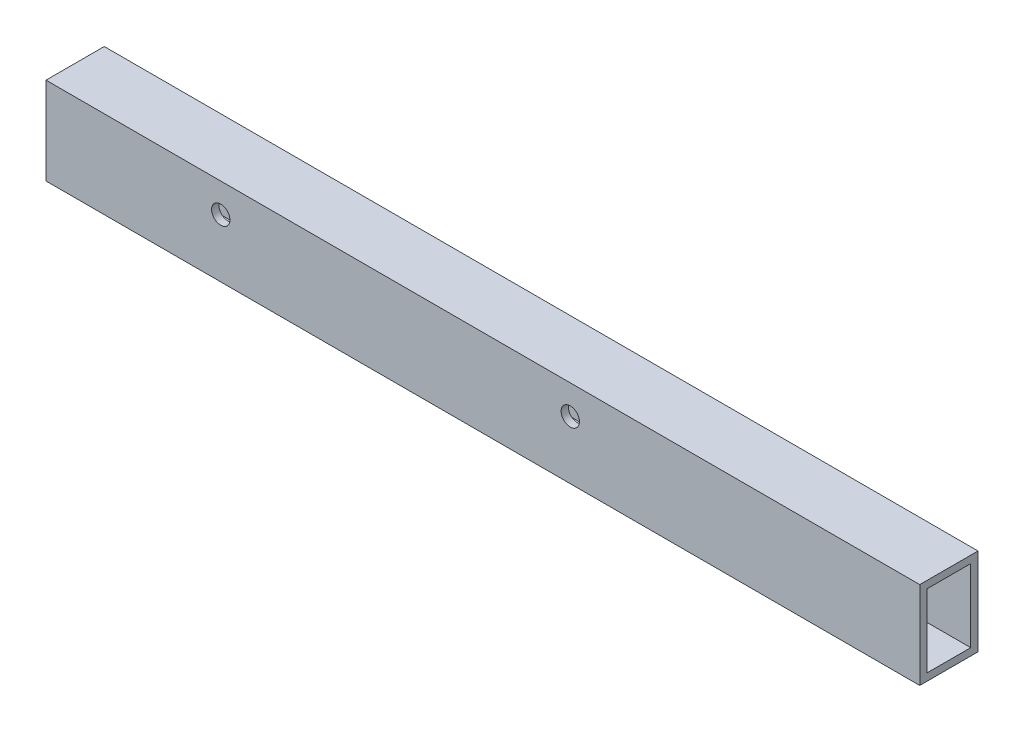
from build123d import *

# Parameters (mm, degrees)
SKETCH1_W           = 25.4
SKETCH1_H           = 38.1
SKETCH1_W_2         = 19.05
SKETCH1_H_2         = 31.75
BOSS_EXTRUDE1_DEPTH = 381
SKETCH2_R           = 4
CUT_EXTRUDE1_DEPTH  = 26.4


with BuildPart() as part:
    # Sketch1 → Boss-Extrude1 (new body)
    with BuildSketch(Plane(origin=(0, 0, 0), x_dir=(0, 0, -1), z_dir=(1, 0, 0))):
        Rectangle(SKETCH1_W, SKETCH1_H)
        Rectangle(SKETCH1_W_2, SKETCH1_H_2, mode=Mode.SUBTRACT)
    extrude(amount=BOSS_EXTRUDE1_DEPTH)

    # Sketch2 → Cut-Extrude1 (cut, through all)
    with BuildSketch(Plane(origin=(0, 0, -12.7), x_dir=(-1, 0, 0), z_dir=(0, 0, -1))):
        with Locations((-76.2, 6.35)):
            Circle(SKETCH2_R)
        with Locations((-228.6, 6.35)):
            Circle(SKETCH2_R)
    extrude(amount=-CUT_EXTRUDE1_DEPTH, mode=Mode.SUBTRACT)


solid = part.part
